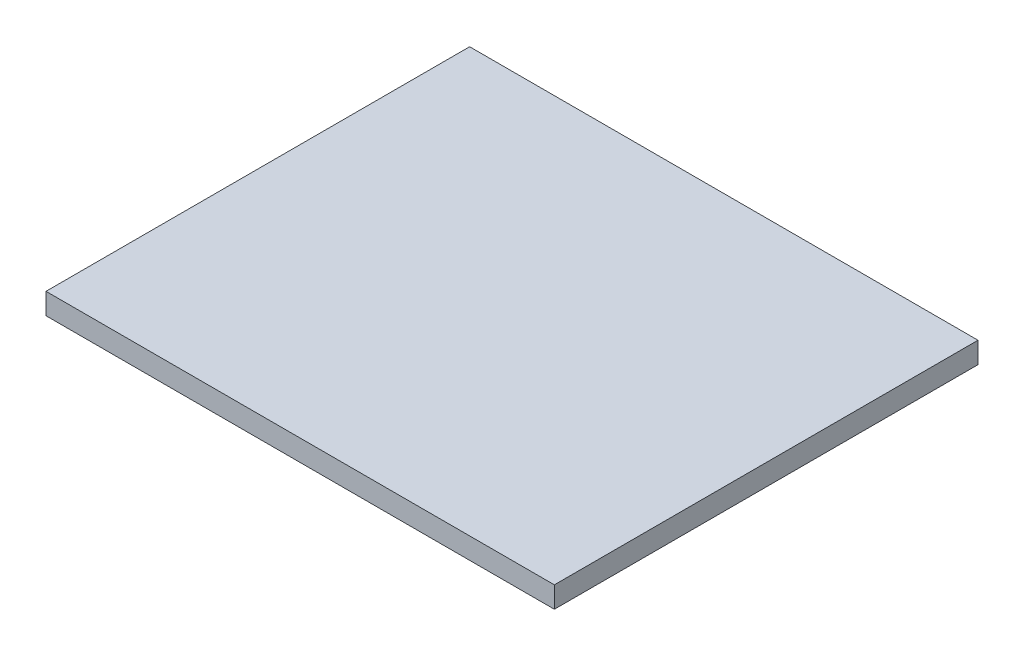
from build123d import *

# Parameters (mm, degrees)
SKETCH1_W           = 152.4
SKETCH1_H           = 127
BOSS_EXTRUDE1_DEPTH = 6.35


with BuildPart() as part:
    # Sketch1 → Boss-Extrude1 (new body)
    with BuildSketch(Plane(origin=(0, 0, 0), x_dir=(1, 0, 0), z_dir=(0, 1, 0))):
        Rectangle(SKETCH1_W, SKETCH1_H)
    extrude(amount=BOSS_EXTRUDE1_DEPTH)


solid = part.part
